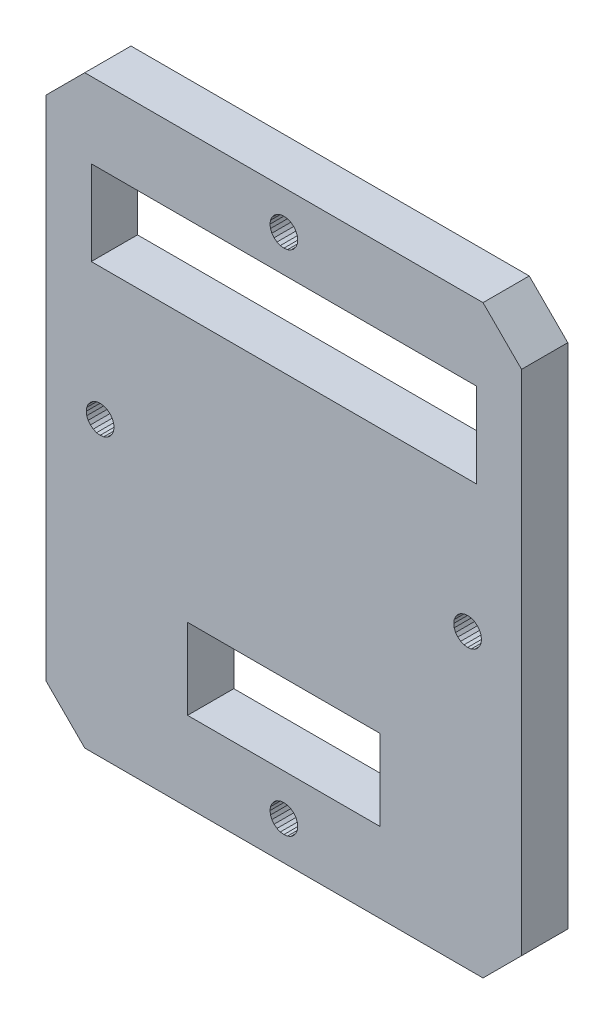
from build123d import *

# Parameters (mm, degrees)
SKETCH1_W           = 24.999989911
SKETCH1_H           = 10.457138346
SKETCH1_W_2         = 49.999979698
SKETCH1_H_2         = 10.999995004
BOSS_EXTRUDE1_DEPTH = 6


with BuildPart() as part:
    # Sketch1 → Boss-Extrude1 (new body)
    with BuildSketch(Plane.XY):
        Polygon((-13.869587182, 182.416079474), (-65.562023318, 182.416079474), (-70.562021318, 187.416077474), (-70.562021318, 253.330336135), (-65.562023318, 258.330334135), (-13.869587203, 258.330334135), (-8.86958931, 253.330336243), (-8.869589201, 187.416077455), align=None)
        with Locations((-39.715805198, 197.994644352)):
            Rectangle(SKETCH1_W, SKETCH1_H, mode=Mode.SUBTRACT)
        with Locations((-39.71580491, 243.023197048)):
            Rectangle(SKETCH1_W_2, SKETCH1_H_2, mode=Mode.SUBTRACT)
        Polygon((-64.027895433, 218.634541052), (-63.562021338, 218.573207564), (-63.096147243, 218.634541052), (-62.662021698, 218.81436174), (-62.289229641, 219.100415147), (-62.003176235, 219.473207204), (-61.823355546, 219.907332749), (-61.762022058, 220.373206844), (-61.823355546, 220.839080938), (-62.003176235, 221.273206484), (-62.289229641, 221.645998541), (-62.662021698, 221.932051947), (-63.096147243, 222.111872635), (-63.562021338, 222.173206124), (-64.027895433, 222.111872635), (-64.462020978, 221.932051947), (-64.834813035, 221.645998541), (-65.120866442, 221.273206484), (-65.30068713, 220.839080938), (-65.362020618, 220.373206844), (-65.30068713, 219.907332749), (-65.120866442, 219.473207204), (-64.834813035, 219.100415147), (-64.462020978, 218.81436174), align=None, mode=Mode.SUBTRACT)
        Polygon((-15.869589261, 222.173206124), (-16.335463356, 222.111872635), (-16.769588901, 221.932051947), (-17.142380958, 221.645998541), (-17.428434364, 221.273206484), (-17.608255053, 220.839080938), (-17.669588541, 220.373206844), (-17.608255053, 219.907332749), (-17.428434364, 219.473207204), (-17.142380958, 219.100415147), (-16.769588901, 218.81436174), (-16.335463356, 218.634541052), (-15.869589261, 218.573207564), (-15.403715166, 218.634541052), (-14.969589621, 218.81436174), (-14.596797564, 219.100415147), (-14.310744158, 219.473207204), (-14.130923469, 219.907332749), (-14.069589981, 220.373206844), (-14.130923469, 220.839080938), (-14.310744158, 221.273206484), (-14.596797564, 221.645998541), (-14.969589621, 221.932051947), (-15.403715166, 222.111872635), align=None, mode=Mode.SUBTRACT)
        Polygon((-37.977139428, 187.881953608), (-38.156960116, 188.316079153), (-38.443013523, 188.68887121), (-38.81580558, 188.974924616), (-39.249931125, 189.154745305), (-39.71580522, 189.216078793), (-40.181679314, 189.154745305), (-40.61580486, 188.974924616), (-40.988596917, 188.68887121), (-41.274650323, 188.316079153), (-41.454471012, 187.881953608), (-41.5158045, 187.416079513), (-41.454471012, 186.950205418), (-41.274650323, 186.516079873), (-40.988596917, 186.143287816), (-40.61580486, 185.857234409), (-40.181679314, 185.677413721), (-39.71580522, 185.616080233), (-39.249931125, 185.677413721), (-38.81580558, 185.857234409), (-38.443013523, 186.143287816), (-38.156960116, 186.516079873), (-37.977139428, 186.950205418), (-37.91580594, 187.416079513), align=None, mode=Mode.SUBTRACT)
        Polygon((-37.977139428, 252.86446006), (-37.91580594, 253.330334155), (-37.977139428, 253.79620825), (-38.156960116, 254.230333795), (-38.443013523, 254.603125852), (-38.81580558, 254.889179258), (-39.249931125, 255.068999947), (-39.71580522, 255.130333435), (-40.181679314, 255.068999947), (-40.61580486, 254.889179258), (-40.988596917, 254.603125852), (-41.274650323, 254.230333795), (-41.454471012, 253.79620825), (-41.5158045, 253.330334155), (-41.454471012, 252.86446006), (-41.274650323, 252.430334515), (-40.988596917, 252.057542458), (-40.61580486, 251.771489052), (-40.181679314, 251.591668363), (-39.71580522, 251.530334875), (-39.249931125, 251.591668363), (-38.81580558, 251.771489052), (-38.443013523, 252.057542458), (-38.156960116, 252.430334515), align=None, mode=Mode.SUBTRACT)
    extrude(amount=BOSS_EXTRUDE1_DEPTH)


solid = part.part
